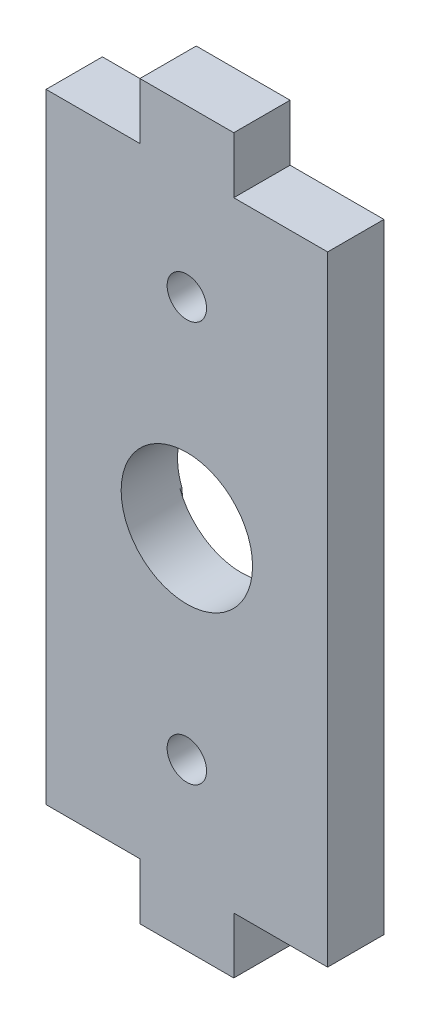
from build123d import *

# Parameters (mm, degrees)
CORTE_EXTERIOR_R        = 1.05
CORTE_EXTERIOR_R_2      = 3.5
SALIENTE_EXTRUIR1_DEPTH = 3
CORTAR_EXTRUIR1_DEPTH   = 0.1


with BuildPart() as part:
    # Corte exterior → Saliente-Extruir1 (new body)
    with BuildSketch(Plane.XY):
        Polygon((28.7, -4.2), (23.7, -4.2), (23.7, -1.2), (18.7, -1.2), (18.7, 9.8), (18.7, 31.8), (23.7, 31.8), (23.7, 34.8), (28.7, 34.8), (28.7, 31.8), (33.7, 31.8), (33.7, 15.8), (33.7, -1.2), (28.7, -1.2), align=None)
        with Locations((26.2, 25.972229454)):
            Circle(CORTE_EXTERIOR_R, mode=Mode.SUBTRACT)
        with Locations((26.2, 4.627770547)):
            Circle(CORTE_EXTERIOR_R, mode=Mode.SUBTRACT)
        with Locations((26.2, 15.3)):
            Circle(CORTE_EXTERIOR_R_2, mode=Mode.SUBTRACT)
    extrude(amount=SALIENTE_EXTRUIR1_DEPTH)

    # Grabado Superficie → Cortar-Extruir1 (cut)
    with BuildSketch(Plane.XY):
        with BuildLine():
            Line((22.930825792, 16.55), (24.2, 29.3))
            ThreePointArc((24.2, 29.3), (26.101579532, 31.297576885), (28.190313411, 29.496602453))
            Line((28.190313411, 29.496602453), (29.469174208, 16.55))
            ThreePointArc((29.469174208, 16.55), (26.2, 18.8), (22.930825792, 16.55))
        make_face()
        with BuildLine():
            Line((29.469174208, 14.05), (28.2, 1))
            ThreePointArc((28.2, 1), (26.2, -1), (24.2, 1))
            Line((24.2, 1), (22.930825792, 14.05))
            ThreePointArc((22.930825792, 14.05), (26.2, 11.8), (29.469174208, 14.05))
        make_face()
    extrude(amount=CORTAR_EXTRUIR1_DEPTH, mode=Mode.SUBTRACT)


solid = part.part
